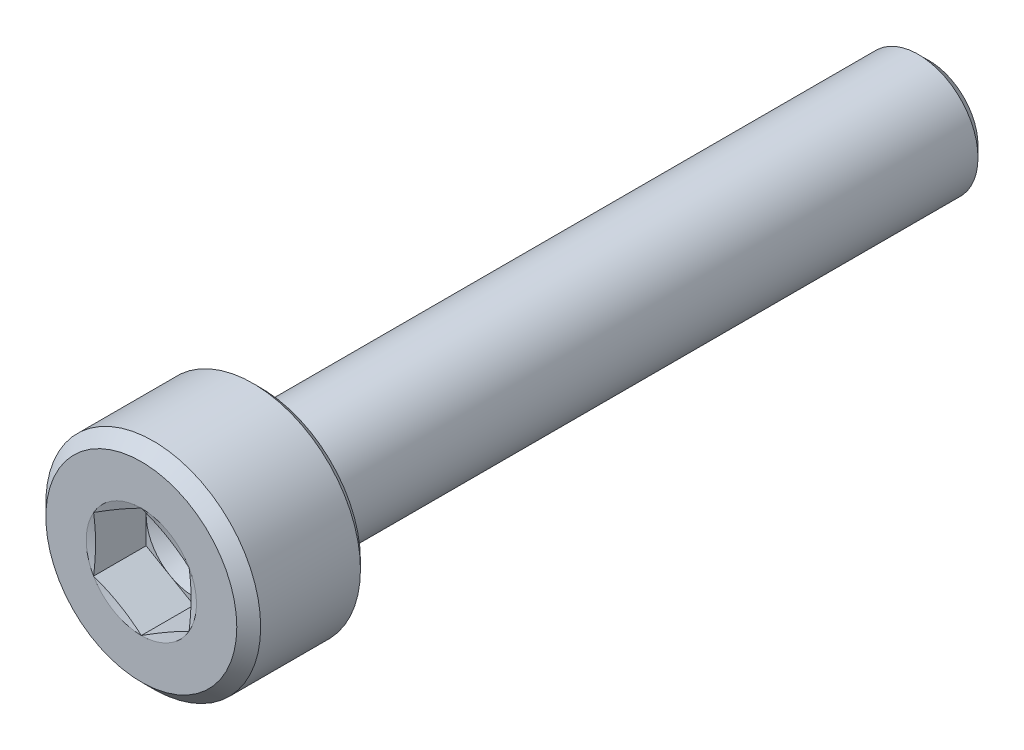
from build123d import *

# Parameters (mm, degrees)
CUT_EXTRUDE1_DEPTH = 1.1


with BuildPart() as part:
    # Sketch1 → Revolve1 (revolve)
    with BuildSketch(Plane(origin=(0, 0, 0), x_dir=(0, 0, -1), z_dir=(1, 0, 0))):
        with BuildLine():
            Line((0, 0), (0, 2))
            Line((0, 2), (0.25, 2.25))
            Line((0.25, 2.25), (2.34, 2.25))
            Line((2.34, 2.25), (2.5, 2.09))
            Line((2.5, 2.09), (2.5, 1.55))
            ThreePointArc((2.5, 1.55), (2.515193643, 1.49701055), (2.556157637, 1.460123155))
            Line((2.556157637, 1.460123155), (2.966157637, 1.260123155))
            ThreePointArc((2.966157637, 1.260123155), (2.98750205, 1.25256365), (3.01, 1.25))
            Line((3.01, 1.25), (16.275, 1.25))
            Line((16.275, 1.25), (16.5, 1.025))
            Line((16.5, 1.025), (16.5, 0))
            Line((16.5, 0), (0, 0))
        make_face()
    revolve(axis=Axis((0, 0, 0), (0, 0, -1)))

    # Sketch2 → Cut-Extrude1 (cut)
    with BuildSketch(Plane.XY):
        Polygon((0, 1.154700538), (-1, 0.577350269), (-1, -0.577350269), (0, -1.154700538), (1, -0.577350269), (1, 0.577350269), align=None)
    extrude(amount=-CUT_EXTRUDE1_DEPTH, mode=Mode.SUBTRACT)

    # Sketch3 → Cut-Revolve2 (revolve, cut)
    with BuildSketch(Plane(origin=(0, 0, 0), x_dir=(0, 0, -1), z_dir=(1, 0, 0))):
        Polygon((1.1, 0), (1.1, 1), (1.677350269, 0), align=None)
    revolve(axis=Axis((0, 0, -1.1), (0, 0, -1)), mode=Mode.SUBTRACT)

    # Sketch4 → Cut-Revolve3 (revolve, cut)
    with BuildSketch(Plane(origin=(0, 0, 0), x_dir=(0, 0, -1), z_dir=(1, 0, 0))):
        Polygon((0, 1.154700538), (0, 1), (0.041451884, 1), align=None)
    revolve(axis=Axis((0, 0, 0), (0, 0, -1)), mode=Mode.SUBTRACT)


solid = part.part
